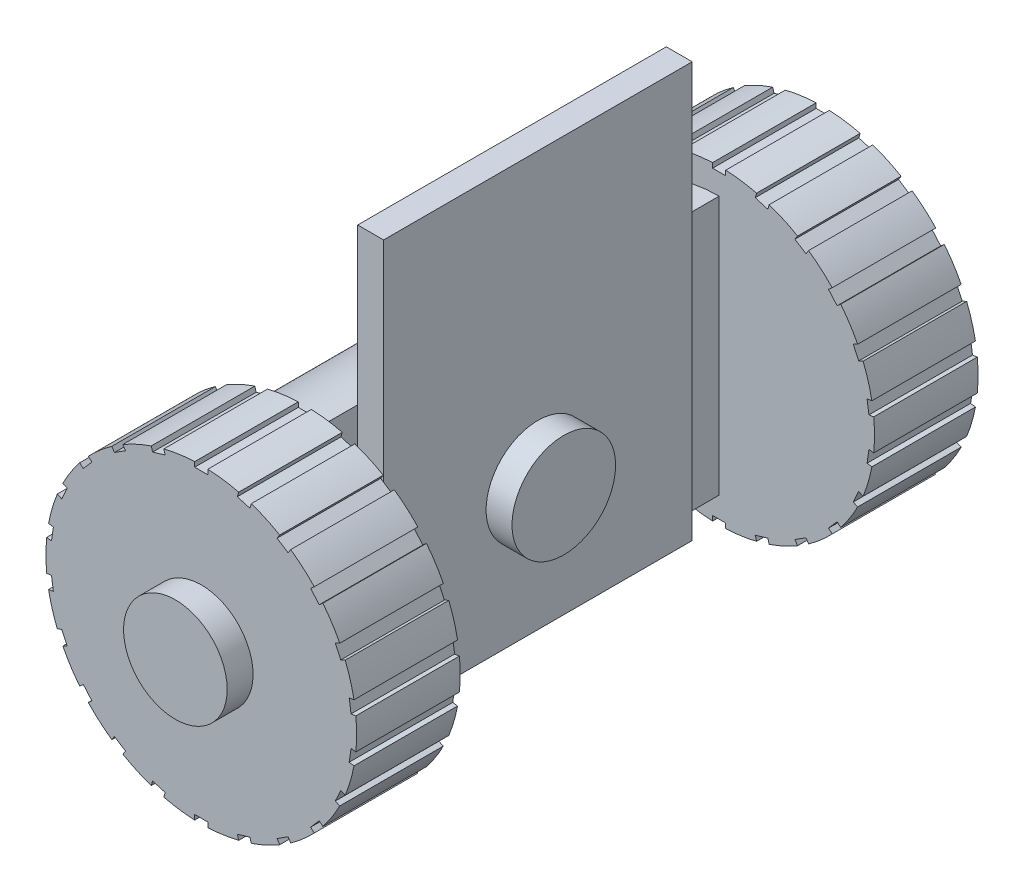
from build123d import *

# Parameters (mm, degrees)
SKETCH1_R                = 30
BOSS_EXTRUDE1_DEPTH      = 20
SKETCH2_R                = 10
BOSS_EXTRUDE2_DEPTH      = 5
SKETCH3_R                = 25
BOSS_EXTRUDE3_DEPTH      = 80
SKETCH4_W                = 25
SKETCH4_H                = 80
CUT_EXTRUDE1_DEPTH       = 80
CUT_EXTRUDE1_DEPTH_BACK  = 80
SKETCH5_W                = 2.53240617
SKETCH5_H                = 1.928101898
CUT_EXTRUDE2_DEPTH       = 100
CIRPATTERN1_COUNT        = 22
MIRROR3_COPY_1_SKETCH_W  = 2.53240617
MIRROR3_COPY_1_SKETCH_H  = 1.928101898
MIRROR3_COPY_1_DEPTH     = 100
MIRROR3_COPY_2_SKETCH_W  = 2.53240617
MIRROR3_COPY_2_SKETCH_H  = 1.928101898
MIRROR3_COPY_2_DEPTH     = 100
MIRROR3_COPY_3_SKETCH_W  = 2.53240617
MIRROR3_COPY_3_SKETCH_H  = 1.928101898
MIRROR3_COPY_3_DEPTH     = 100
MIRROR3_COPY_4_SKETCH_W  = 2.53240617
MIRROR3_COPY_4_SKETCH_H  = 1.928101898
MIRROR3_COPY_4_DEPTH     = 100
MIRROR3_COPY_5_SKETCH_W  = 2.53240617
MIRROR3_COPY_5_SKETCH_H  = 1.928101898
MIRROR3_COPY_5_DEPTH     = 100
MIRROR3_COPY_6_SKETCH_W  = 2.53240617
MIRROR3_COPY_6_SKETCH_H  = 1.928101898
MIRROR3_COPY_6_DEPTH     = 100
MIRROR3_COPY_7_SKETCH_W  = 2.53240617
MIRROR3_COPY_7_SKETCH_H  = 1.928101898
MIRROR3_COPY_7_DEPTH     = 100
MIRROR3_COPY_8_SKETCH_W  = 2.53240617
MIRROR3_COPY_8_SKETCH_H  = 1.928101898
MIRROR3_COPY_8_DEPTH     = 100
MIRROR3_COPY_9_SKETCH_W  = 2.53240617
MIRROR3_COPY_9_SKETCH_H  = 1.928101898
MIRROR3_COPY_9_DEPTH     = 100
MIRROR3_COPY_10_SKETCH_W = 2.53240617
MIRROR3_COPY_10_SKETCH_H = 1.928101898
MIRROR3_COPY_10_DEPTH    = 100
MIRROR3_COPY_11_SKETCH_W = 2.53240617
MIRROR3_COPY_11_SKETCH_H = 1.928101898
MIRROR3_COPY_11_DEPTH    = 100
MIRROR3_COPY_12_SKETCH_W = 2.53240617
MIRROR3_COPY_12_SKETCH_H = 1.928101898
MIRROR3_COPY_12_DEPTH    = 100
MIRROR3_COPY_13_SKETCH_W = 2.53240617
MIRROR3_COPY_13_SKETCH_H = 1.928101898
MIRROR3_COPY_13_DEPTH    = 100
MIRROR3_COPY_14_SKETCH_W = 2.53240617
MIRROR3_COPY_14_SKETCH_H = 1.928101898
MIRROR3_COPY_14_DEPTH    = 100
MIRROR3_COPY_15_SKETCH_W = 2.53240617
MIRROR3_COPY_15_SKETCH_H = 1.928101898
MIRROR3_COPY_15_DEPTH    = 100
MIRROR3_COPY_16_SKETCH_W = 2.53240617
MIRROR3_COPY_16_SKETCH_H = 1.928101898
MIRROR3_COPY_16_DEPTH    = 100
MIRROR3_COPY_17_SKETCH_W = 2.53240617
MIRROR3_COPY_17_SKETCH_H = 1.928101898
MIRROR3_COPY_17_DEPTH    = 100
MIRROR3_COPY_18_SKETCH_W = 2.53240617
MIRROR3_COPY_18_SKETCH_H = 1.928101898
MIRROR3_COPY_18_DEPTH    = 100
MIRROR3_COPY_19_SKETCH_W = 2.53240617
MIRROR3_COPY_19_SKETCH_H = 1.928101898
MIRROR3_COPY_19_DEPTH    = 100
MIRROR3_COPY_20_SKETCH_W = 2.53240617
MIRROR3_COPY_20_SKETCH_H = 1.928101898
MIRROR3_COPY_20_DEPTH    = 100
MIRROR3_COPY_21_SKETCH_W = 2.53240617
MIRROR3_COPY_21_SKETCH_H = 1.928101898
MIRROR3_COPY_21_DEPTH    = 100
SKETCH6_W                = 59.591223088
SKETCH6_H                = 30.073823918
SKETCH6_H_2              = 50
BOSS_EXTRUDE4_DEPTH      = 5
SKETCH7_R                = 10
BOSS_EXTRUDE5_DEPTH      = 5


with BuildPart() as part:
    # Sketch1 → Boss-Extrude1 (new body)
    with BuildSketch(Plane.XY):
        Circle(SKETCH1_R)
    boss_extrude1 = extrude(amount=BOSS_EXTRUDE1_DEPTH)

    # Sketch2 → Boss-Extrude2 (add)
    with BuildSketch(Plane.XY.offset(20)):
        Circle(SKETCH2_R)
    boss_extrude2 = extrude(amount=BOSS_EXTRUDE2_DEPTH)

    # Sketch3 → Boss-Extrude3 (add)
    with BuildSketch(Plane(origin=(0, 0, 0), x_dir=(-1, 0, 0), z_dir=(0, 0, -1))):
        Circle(SKETCH3_R)
    extrude(amount=BOSS_EXTRUDE3_DEPTH)

    # Sketch4 → Cut-Extrude1 (cut, two sides)
    with BuildSketch(Plane(origin=(0, 0, 0), x_dir=(1, 0, 0), z_dir=(0, 1, 0))) as cut_extrude1_sk:
        with Locations((12.5, 40)):
            Rectangle(SKETCH4_W, SKETCH4_H)
    extrude(amount=CUT_EXTRUDE1_DEPTH, mode=Mode.SUBTRACT)
    extrude(cut_extrude1_sk.sketch, amount=-CUT_EXTRUDE1_DEPTH_BACK, mode=Mode.SUBTRACT)

    # Sketch5 → Cut-Extrude2 (cut)
    with BuildSketch(Plane.XY.offset(20)):
        with Locations((0, 30)):
            Rectangle(SKETCH5_W, SKETCH5_H)
    cut_extrude2 = extrude(amount=-CUT_EXTRUDE2_DEPTH, mode=Mode.SUBTRACT)

    # CirPattern1: Cut-Extrude2 ×22 about axis
    cirpattern1_axis = Axis((0, 0, 0), (0, 0, 1))
    for i in range(1, CIRPATTERN1_COUNT):
        add(cut_extrude2.rotate(cirpattern1_axis, i * 360 / CIRPATTERN1_COUNT), mode=Mode.SUBTRACT)

    # Mirror3: Boss-Extrude2, Boss-Extrude1, Cut-Extrude2 across plane
    add(boss_extrude2.mirror(Plane.XY.offset(-40)))
    add(boss_extrude1.mirror(Plane.XY.offset(-40)))
    add(cut_extrude2.mirror(Plane.XY.offset(-40)), mode=Mode.SUBTRACT)

    # Mirror3 copy 1 sketch → Mirror3 copy 1 (cut)
    with BuildSketch(Plane(origin=(0, 0, -100), x_dir=(0.959492974, 0.281732557, 0), z_dir=(0, 0, -1))):
        with Locations((0, -30)):
            Rectangle(MIRROR3_COPY_1_SKETCH_W, MIRROR3_COPY_1_SKETCH_H)
    extrude(amount=-MIRROR3_COPY_1_DEPTH, mode=Mode.SUBTRACT)

    # Mirror3 copy 2 sketch → Mirror3 copy 2 (cut)
    with BuildSketch(Plane(origin=(0, 0, -100), x_dir=(0.841253533, 0.540640817, 0), z_dir=(0, 0, -1))):
        with Locations((0, -30)):
            Rectangle(MIRROR3_COPY_2_SKETCH_W, MIRROR3_COPY_2_SKETCH_H)
    extrude(amount=-MIRROR3_COPY_2_DEPTH, mode=Mode.SUBTRACT)

    # Mirror3 copy 3 sketch → Mirror3 copy 3 (cut)
    with BuildSketch(Plane(origin=(0, 0, -100), x_dir=(0.654860734, 0.755749574, 0), z_dir=(0, 0, -1))):
        with Locations((0, -30)):
            Rectangle(MIRROR3_COPY_3_SKETCH_W, MIRROR3_COPY_3_SKETCH_H)
    extrude(amount=-MIRROR3_COPY_3_DEPTH, mode=Mode.SUBTRACT)

    # Mirror3 copy 4 sketch → Mirror3 copy 4 (cut)
    with BuildSketch(Plane(origin=(0, 0, -100), x_dir=(0.415415013, 0.909631995, 0), z_dir=(0, 0, -1))):
        with Locations((0, -30)):
            Rectangle(MIRROR3_COPY_4_SKETCH_W, MIRROR3_COPY_4_SKETCH_H)
    extrude(amount=-MIRROR3_COPY_4_DEPTH, mode=Mode.SUBTRACT)

    # Mirror3 copy 5 sketch → Mirror3 copy 5 (cut)
    with BuildSketch(Plane(origin=(0, 0, -100), x_dir=(0.142314838, 0.989821442, 0), z_dir=(0, 0, -1))):
        with Locations((0, -30)):
            Rectangle(MIRROR3_COPY_5_SKETCH_W, MIRROR3_COPY_5_SKETCH_H)
    extrude(amount=-MIRROR3_COPY_5_DEPTH, mode=Mode.SUBTRACT)

    # Mirror3 copy 6 sketch → Mirror3 copy 6 (cut)
    with BuildSketch(Plane(origin=(0, 0, -100), x_dir=(-0.142314838, 0.989821442, 0), z_dir=(0, 0, -1))):
        with Locations((0, -30)):
            Rectangle(MIRROR3_COPY_6_SKETCH_W, MIRROR3_COPY_6_SKETCH_H)
    extrude(amount=-MIRROR3_COPY_6_DEPTH, mode=Mode.SUBTRACT)

    # Mirror3 copy 7 sketch → Mirror3 copy 7 (cut)
    with BuildSketch(Plane(origin=(0, 0, -100), x_dir=(-0.415415013, 0.909631995, 0), z_dir=(0, 0, -1))):
        with Locations((0, -30)):
            Rectangle(MIRROR3_COPY_7_SKETCH_W, MIRROR3_COPY_7_SKETCH_H)
    extrude(amount=-MIRROR3_COPY_7_DEPTH, mode=Mode.SUBTRACT)

    # Mirror3 copy 8 sketch → Mirror3 copy 8 (cut)
    with BuildSketch(Plane(origin=(0, 0, -100), x_dir=(-0.654860734, 0.755749574, 0), z_dir=(0, 0, -1))):
        with Locations((0, -30)):
            Rectangle(MIRROR3_COPY_8_SKETCH_W, MIRROR3_COPY_8_SKETCH_H)
    extrude(amount=-MIRROR3_COPY_8_DEPTH, mode=Mode.SUBTRACT)

    # Mirror3 copy 9 sketch → Mirror3 copy 9 (cut)
    with BuildSketch(Plane(origin=(0, 0, -100), x_dir=(-0.841253533, 0.540640817, 0), z_dir=(0, 0, -1))):
        with Locations((0, -30)):
            Rectangle(MIRROR3_COPY_9_SKETCH_W, MIRROR3_COPY_9_SKETCH_H)
    extrude(amount=-MIRROR3_COPY_9_DEPTH, mode=Mode.SUBTRACT)

    # Mirror3 copy 10 sketch → Mirror3 copy 10 (cut)
    with BuildSketch(Plane(origin=(0, 0, -100), x_dir=(-0.959492974, 0.281732557, 0), z_dir=(0, 0, -1))):
        with Locations((0, -30)):
            Rectangle(MIRROR3_COPY_10_SKETCH_W, MIRROR3_COPY_10_SKETCH_H)
    extrude(amount=-MIRROR3_COPY_10_DEPTH, mode=Mode.SUBTRACT)

    # Mirror3 copy 11 sketch → Mirror3 copy 11 (cut)
    with BuildSketch(Plane(origin=(0, 0, -100), x_dir=(-1, 0, 0), z_dir=(0, 0, -1))):
        with Locations((0, -30)):
            Rectangle(MIRROR3_COPY_11_SKETCH_W, MIRROR3_COPY_11_SKETCH_H)
    extrude(amount=-MIRROR3_COPY_11_DEPTH, mode=Mode.SUBTRACT)

    # Mirror3 copy 12 sketch → Mirror3 copy 12 (cut)
    with BuildSketch(Plane(origin=(0, 0, -100), x_dir=(-0.959492974, -0.281732557, 0), z_dir=(0, 0, -1))):
        with Locations((0, -30)):
            Rectangle(MIRROR3_COPY_12_SKETCH_W, MIRROR3_COPY_12_SKETCH_H)
    extrude(amount=-MIRROR3_COPY_12_DEPTH, mode=Mode.SUBTRACT)

    # Mirror3 copy 13 sketch → Mirror3 copy 13 (cut)
    with BuildSketch(Plane(origin=(0, 0, -100), x_dir=(-0.841253533, -0.540640817, 0), z_dir=(0, 0, -1))):
        with Locations((0, -30)):
            Rectangle(MIRROR3_COPY_13_SKETCH_W, MIRROR3_COPY_13_SKETCH_H)
    extrude(amount=-MIRROR3_COPY_13_DEPTH, mode=Mode.SUBTRACT)

    # Mirror3 copy 14 sketch → Mirror3 copy 14 (cut)
    with BuildSketch(Plane(origin=(0, 0, -100), x_dir=(-0.654860734, -0.755749574, 0), z_dir=(0, 0, -1))):
        with Locations((0, -30)):
            Rectangle(MIRROR3_COPY_14_SKETCH_W, MIRROR3_COPY_14_SKETCH_H)
    extrude(amount=-MIRROR3_COPY_14_DEPTH, mode=Mode.SUBTRACT)

    # Mirror3 copy 15 sketch → Mirror3 copy 15 (cut)
    with BuildSketch(Plane(origin=(0, 0, -100), x_dir=(-0.415415013, -0.909631995, 0), z_dir=(0, 0, -1))):
        with Locations((0, -30)):
            Rectangle(MIRROR3_COPY_15_SKETCH_W, MIRROR3_COPY_15_SKETCH_H)
    extrude(amount=-MIRROR3_COPY_15_DEPTH, mode=Mode.SUBTRACT)

    # Mirror3 copy 16 sketch → Mirror3 copy 16 (cut)
    with BuildSketch(Plane(origin=(0, 0, -100), x_dir=(-0.142314838, -0.989821442, 0), z_dir=(0, 0, -1))):
        with Locations((0, -30)):
            Rectangle(MIRROR3_COPY_16_SKETCH_W, MIRROR3_COPY_16_SKETCH_H)
    extrude(amount=-MIRROR3_COPY_16_DEPTH, mode=Mode.SUBTRACT)

    # Mirror3 copy 17 sketch → Mirror3 copy 17 (cut)
    with BuildSketch(Plane(origin=(0, 0, -100), x_dir=(0.142314838, -0.989821442, 0), z_dir=(0, 0, -1))):
        with Locations((0, -30)):
            Rectangle(MIRROR3_COPY_17_SKETCH_W, MIRROR3_COPY_17_SKETCH_H)
    extrude(amount=-MIRROR3_COPY_17_DEPTH, mode=Mode.SUBTRACT)

    # Mirror3 copy 18 sketch → Mirror3 copy 18 (cut)
    with BuildSketch(Plane(origin=(0, 0, -100), x_dir=(0.415415013, -0.909631995, 0), z_dir=(0, 0, -1))):
        with Locations((0, -30)):
            Rectangle(MIRROR3_COPY_18_SKETCH_W, MIRROR3_COPY_18_SKETCH_H)
    extrude(amount=-MIRROR3_COPY_18_DEPTH, mode=Mode.SUBTRACT)

    # Mirror3 copy 19 sketch → Mirror3 copy 19 (cut)
    with BuildSketch(Plane(origin=(0, 0, -100), x_dir=(0.654860734, -0.755749574, 0), z_dir=(0, 0, -1))):
        with Locations((0, -30)):
            Rectangle(MIRROR3_COPY_19_SKETCH_W, MIRROR3_COPY_19_SKETCH_H)
    extrude(amount=-MIRROR3_COPY_19_DEPTH, mode=Mode.SUBTRACT)

    # Mirror3 copy 20 sketch → Mirror3 copy 20 (cut)
    with BuildSketch(Plane(origin=(0, 0, -100), x_dir=(0.841253533, -0.540640817, 0), z_dir=(0, 0, -1))):
        with Locations((0, -30)):
            Rectangle(MIRROR3_COPY_20_SKETCH_W, MIRROR3_COPY_20_SKETCH_H)
    extrude(amount=-MIRROR3_COPY_20_DEPTH, mode=Mode.SUBTRACT)

    # Mirror3 copy 21 sketch → Mirror3 copy 21 (cut)
    with BuildSketch(Plane(origin=(0, 0, -100), x_dir=(0.959492974, -0.281732557, 0), z_dir=(0, 0, -1))):
        with Locations((0, -30)):
            Rectangle(MIRROR3_COPY_21_SKETCH_W, MIRROR3_COPY_21_SKETCH_H)
    extrude(amount=-MIRROR3_COPY_21_DEPTH, mode=Mode.SUBTRACT)

    # Sketch6 → Boss-Extrude4 (add)
    with BuildSketch(Plane(origin=(0, 0, 0), x_dir=(0, 0, -1), z_dir=(1, 0, 0))):
        with Locations((40, 40.036911959)):
            Rectangle(SKETCH6_W, SKETCH6_H)
        with Locations((40, 0)):
            Rectangle(SKETCH6_W, SKETCH6_H_2)
    extrude(amount=BOSS_EXTRUDE4_DEPTH)

    # Sketch7 → Boss-Extrude5 (add)
    with BuildSketch(Plane(origin=(5, 0, 0), x_dir=(0, 0, -1), z_dir=(1, 0, 0))):
        with Locations((40, 0)):
            Circle(SKETCH7_R)
    extrude(amount=BOSS_EXTRUDE5_DEPTH)


solid = part.part
